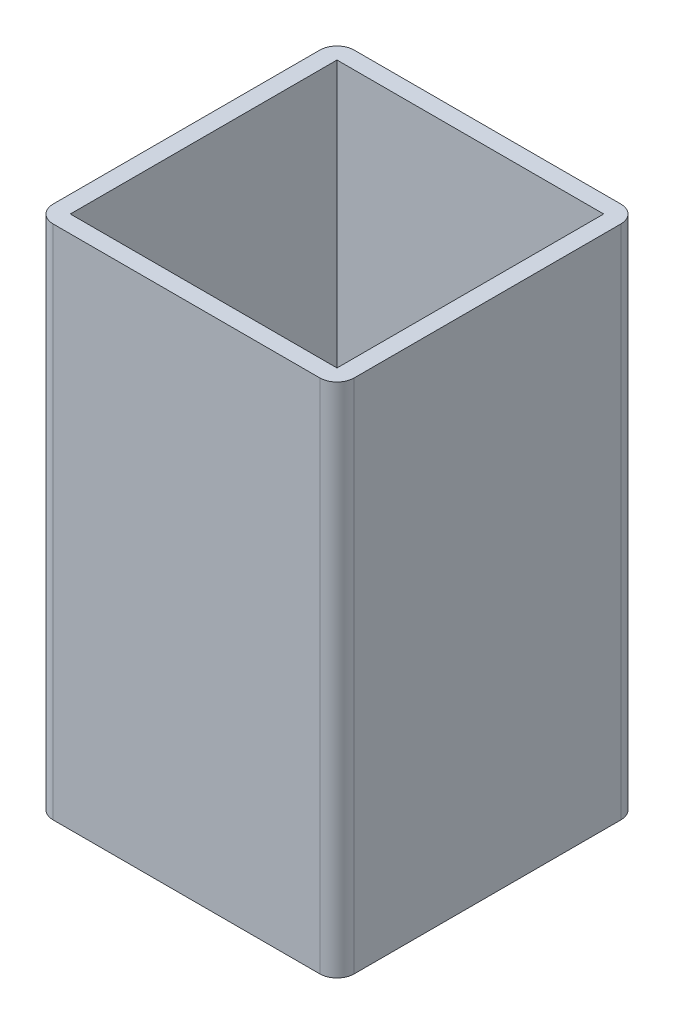
from build123d import *

# Parameters (mm, degrees)
SKETCH1_R           = 4.75
BOSS_EXTRUDE1_DEPTH = 60
SKETCH2_W           = 31
SKETCH2_H           = 31
CUT_EXTRUDE1_DEPTH  = 55


with BuildPart() as part:
    # Sketch1 → Boss-Extrude1 (new body)
    with BuildSketch(Plane(origin=(0, 0, 0), x_dir=(1, 0, 0), z_dir=(0, 1, 0))):
        with BuildLine():
            Line((2, 0), (33, 0))
            ThreePointArc((33, 0), (34.414213562, 0.585786438), (35, 2))
            Line((35, 2), (35, 33))
            ThreePointArc((35, 33), (34.414213562, 34.414213562), (33, 35))
            Line((33, 35), (2, 35))
            ThreePointArc((2, 35), (0.585786438, 34.414213562), (0, 33))
            Line((0, 33), (0, 2))
            ThreePointArc((0, 2), (0.585786438, 0.585786438), (2, 0))
        make_face()
        with Locations((7.5, 17.5)):
            Circle(SKETCH1_R, mode=Mode.SUBTRACT)
        with Locations((27.5, 17.5)):
            Circle(SKETCH1_R, mode=Mode.SUBTRACT)
    extrude(amount=BOSS_EXTRUDE1_DEPTH)

    # Sketch2 → Cut-Extrude1 (cut)
    with BuildSketch(Plane(origin=(0, 60, 0), x_dir=(1, 0, 0), z_dir=(0, 1, 0))):
        with Locations((17.5, 17.5)):
            Rectangle(SKETCH2_W, SKETCH2_H)
    extrude(amount=-CUT_EXTRUDE1_DEPTH, mode=Mode.SUBTRACT)


solid = part.part
